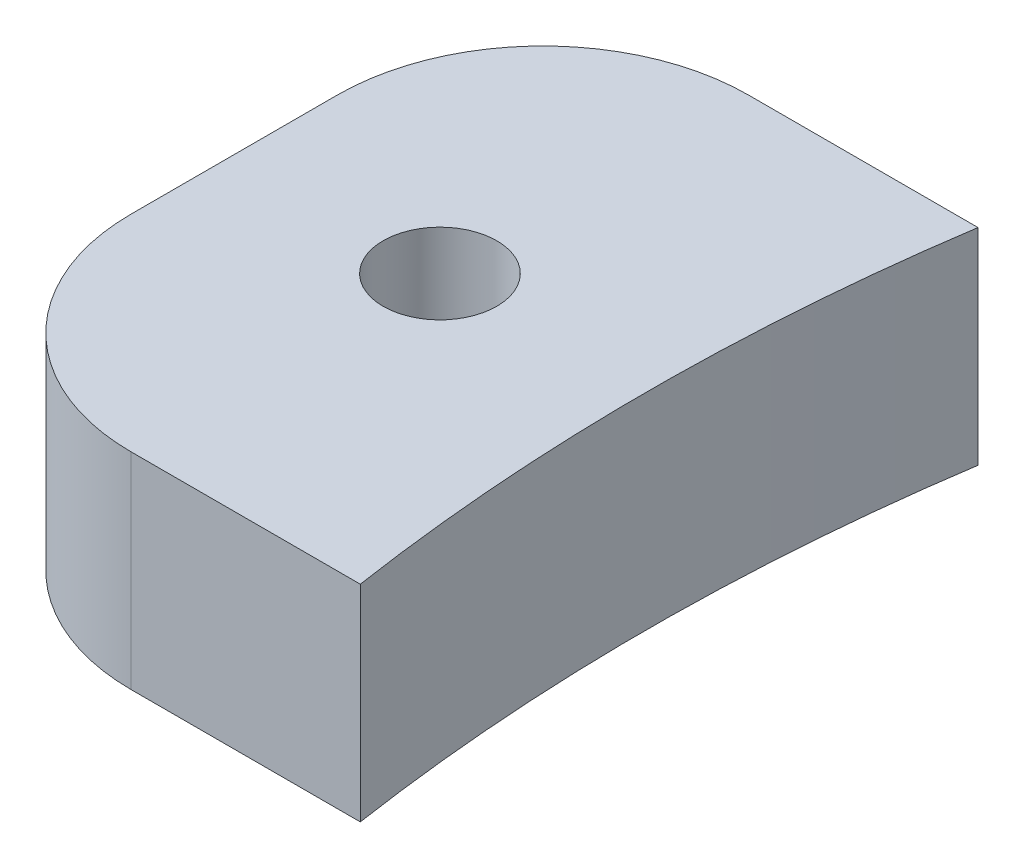
from build123d import *

# Parameters (mm, degrees)
EXTRUDE1_DEPTH                  = 6.35
SKETCH2_R                       = 63.5
CUT_EXTRUDE1_DEPTH              = 6.35
F_6_32_TAPPED_HOLE1_D           = 2.7051
F_6_32_TAPPED_HOLE1_DEPTH       = 9.398
F_6_32_TAPPED_HOLE1_CBORE_D     = 3.5052
F_6_32_TAPPED_HOLE1_CBORE_DEPTH = 7.112
F_6_32_TAPPED_HOLE1_TIP         = 0.81269403


with BuildPart() as part:
    # Sketch1 → Extrude1 (new body)
    with BuildSketch(Plane(origin=(0, 0, 0), x_dir=(1, 0, 0), z_dir=(0, 1, 0))):
        with BuildLine():
            Line((-69.85, 9.525), (0, 9.525))
            Line((0, 9.525), (0, -9.525))
            Line((0, -9.525), (-69.85, -9.525))
            ThreePointArc((-69.85, -9.525), (-74.340128061, -7.665128061), (-76.2, -3.175))
            Line((-76.2, -3.175), (-76.2, 3.175))
            ThreePointArc((-76.2, 3.175), (-74.340128061, 7.665128061), (-69.85, 9.525))
        make_face()
    extrude(amount=EXTRUDE1_DEPTH)

    # Sketch2 → Cut-Extrude1 (cut)
    with BuildSketch(Plane(origin=(0, 6.35, 0), x_dir=(-1, 0, 0), z_dir=(0, 1, 0))):
        Circle(SKETCH2_R)
    extrude(amount=-CUT_EXTRUDE1_DEPTH, mode=Mode.SUBTRACT)

    # #6-32 Tapped Hole1
    with Locations(Plane(origin=(-69.85, 6.35, 0), x_dir=(0, 0, 1), z_dir=(0, 1, 0))):
        with Locations((0, 0)):
            CounterBoreHole(F_6_32_TAPPED_HOLE1_D / 2, F_6_32_TAPPED_HOLE1_CBORE_D / 2, F_6_32_TAPPED_HOLE1_CBORE_DEPTH, depth=F_6_32_TAPPED_HOLE1_DEPTH)
            with Locations((0, 0, -(F_6_32_TAPPED_HOLE1_DEPTH + F_6_32_TAPPED_HOLE1_TIP / 2))):  # 118° drill point
                Cone(0, F_6_32_TAPPED_HOLE1_D / 2, F_6_32_TAPPED_HOLE1_TIP, mode=Mode.SUBTRACT)


solid = part.part
